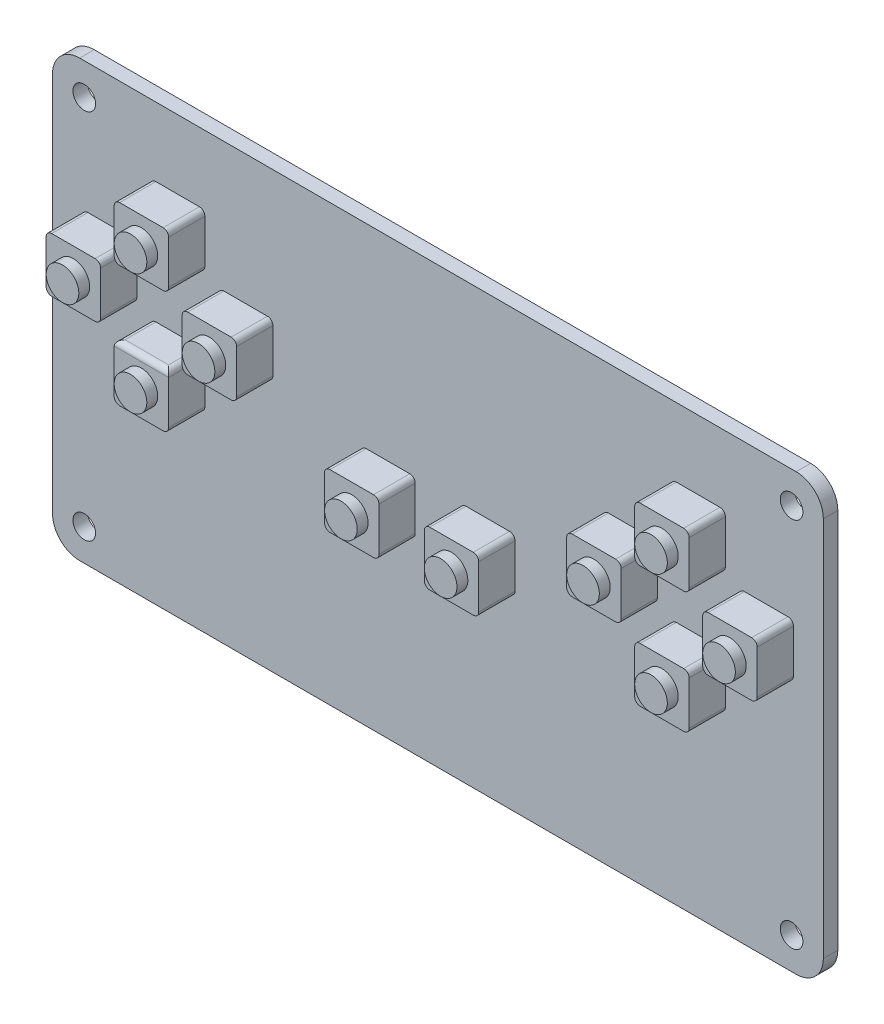
from build123d import *

# Parameters (mm, degrees)
SKETCH1_W           = 85
SKETCH1_H           = 48
BOSS_EXTRUDE1_DEPTH = 1.6
SKETCH2_R           = 1.25
CUT_EXTRUDE1_DEPTH  = 5
FILLET1_R           = 3
SKETCH_1_W          = 6
SKETCH_1_H          = 6
EXTRUDE_1_DEPTH     = 4
SKETCH_2_W          = 6
SKETCH_2_H          = 6
EXTRUDE_2_DEPTH     = 4
SKETCH_3_R          = 1.8
EXTRUDE_3_DEPTH     = 1.2
FILLET_2_R          = 0.6


with BuildPart() as part:
    # Sketch1 → Boss-Extrude1 (new body)
    with BuildSketch(Plane.XY):
        Rectangle(SKETCH1_W, SKETCH1_H)
    extrude(amount=BOSS_EXTRUDE1_DEPTH)

    # Sketch2 → Cut-Extrude1 (cut)
    with BuildSketch(Plane.XY.offset(1.6)):
        with Locations((-39, 20.5)):
            Circle(SKETCH2_R)
        with Locations((39, 20.5)):
            Circle(SKETCH2_R)
        with Locations((39, -20.5)):
            Circle(SKETCH2_R)
        with Locations((-39, -20.5)):
            Circle(SKETCH2_R)
    extrude(amount=-CUT_EXTRUDE1_DEPTH, mode=Mode.SUBTRACT)

    # Fillet1
    fillet1_edges = [part.edges().sort_by_distance(p)[0] for p in [
        (-42.5, 24, 0.8),
        (42.5, 24, 0.8),
        (42.5, -24, 0.8),
        (-42.5, -24, 0.8),
    ]]
    fillet(fillet1_edges, radius=FILLET1_R)

    # 草图1 → 凸台-拉伸1 (add)
    with BuildSketch(Plane.XY.offset(1.6)):
        with Locations((-28.7, 13.4)):
            Rectangle(SKETCH_1_W, SKETCH_1_H)
        with Locations((-28.7, 0)):
            Rectangle(SKETCH_1_W, SKETCH_1_H)
        with Locations((-36.2, 6.7)):
            Rectangle(SKETCH_1_W, SKETCH_1_H)
        with Locations((-21.2, 6.7)):
            Rectangle(SKETCH_1_W, SKETCH_1_H)
    extrude_1 = extrude(amount=EXTRUDE_1_DEPTH)

    # 镜向1: 凸台-拉伸1 across plane
    add(extrude_1.mirror(Plane(origin=(0, 0, 0), x_dir=(0, 0, 1), z_dir=(1, 0, 0))))

    # 草图2 → 凸台-拉伸2 (add)
    with BuildSketch(Plane.XY.offset(1.6)):
        with Locations((-5.5, -0.5)):
            Rectangle(SKETCH_2_W, SKETCH_2_H)
        with Locations((5.5, -0.5)):
            Rectangle(SKETCH_2_W, SKETCH_2_H)
    extrude(amount=EXTRUDE_2_DEPTH)

    # 草图3 → 凸台-拉伸3 (add)
    with BuildSketch(Plane.XY.offset(5.6)):
        with Locations((-36.2, 6.7)):
            Circle(SKETCH_3_R)
        with Locations((-28.7, 13.4)):
            Circle(SKETCH_3_R)
        with Locations((-21.2, 6.7)):
            Circle(SKETCH_3_R)
        with Locations((-28.7, 0)):
            Circle(SKETCH_3_R)
        with Locations((-5.5, -0.5)):
            Circle(SKETCH_3_R)
        with Locations((5.5, -0.5)):
            Circle(SKETCH_3_R)
        with Locations((21.2, 6.7)):
            Circle(SKETCH_3_R)
        with Locations((28.7, 0)):
            Circle(SKETCH_3_R)
        with Locations((36.2, 6.7)):
            Circle(SKETCH_3_R)
        with Locations((28.7, 13.4)):
            Circle(SKETCH_3_R)
    extrude(amount=EXTRUDE_3_DEPTH)

    # 圆角2
    fillet_2_edges = [part.edges().sort_by_distance(p)[0] for p in [
        (25.7, 3, 3.6),
        (25.7, -3, 3.6),
        (31.7, -3, 3.6),
        (31.7, 3, 3.6),
        (39.2, 9.7, 3.6),
        (39.2, 3.7, 3.6),
        (33.2, 3.7, 3.6),
        (33.2, 9.7, 3.6),
        (31.7, 10.4, 3.6),
        (31.7, 16.4, 3.6),
        (25.7, 16.4, 3.6),
        (25.7, 10.4, 3.6),
        (18.2, 3.7, 3.6),
        (18.2, 9.7, 3.6),
        (24.2, 3.7, 3.6),
        (24.2, 9.7, 3.6),
        (8.5, 2.5, 3.6),
        (2.5, 2.5, 3.6),
        (2.5, -3.5, 3.6),
        (8.5, -3.5, 3.6),
        (-2.5, -3.5, 3.6),
        (-8.5, -3.5, 3.6),
        (-8.5, 2.5, 3.6),
        (-2.5, 2.5, 3.6),
        (-24.2, 9.7, 3.6),
        (-18.2, 3.7, 3.6),
        (-18.2, 9.7, 3.6),
        (-24.2, 3.7, 3.6),
        (-31.7, 3, 3.6),
        (-25.7, 3, 3.6),
        (-28.7, 3, 5.6),
        (-25.7, -3, 3.6),
        (-31.7, -3, 3.6),
        (-31.7, 16.4, 3.6),
        (-25.7, 16.4, 3.6),
        (-25.7, 10.4, 3.6),
        (-31.7, 10.4, 3.6),
        (-33.2, 9.7, 3.6),
        (-33.2, 3.7, 3.6),
        (-39.2, 3.7, 3.6),
        (-39.2, 9.7, 3.6),
    ]]
    fillet(fillet_2_edges, radius=FILLET_2_R)


solid = part.part
